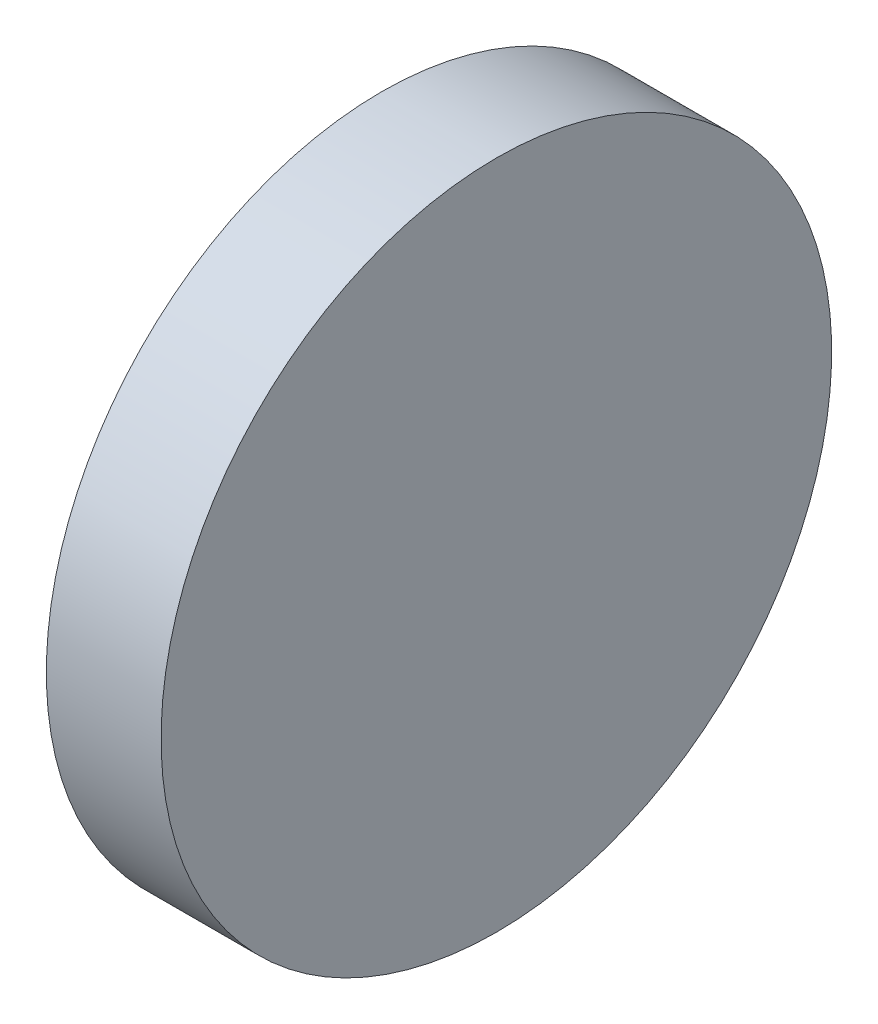
from build123d import *

# Parameters (mm, degrees)
SKETCH1_R           = 74.223475297
SKETCH1_R_2         = 66.342438796
BOSS_EXTRUDE1_DEPTH = 25.4


with BuildPart() as part:
    # Sketch1 → Boss-Extrude1 (new body)
    with BuildSketch(Plane(origin=(-412.116566646, 0, 0), x_dir=(0, 0, -1), z_dir=(1, 0, 0))):
        with Locations(Location((-214.659203324, 41.84959015, 0), (0, 0, 90))):
            Circle(SKETCH1_R)
        with Locations((-214.659203324, 41.84959015)):
            Circle(SKETCH1_R_2, mode=Mode.SUBTRACT)
        with Locations((-214.659203324, 41.84959015)):
            Circle(SKETCH1_R_2)
    extrude(amount=-BOSS_EXTRUDE1_DEPTH)


solid = part.part
